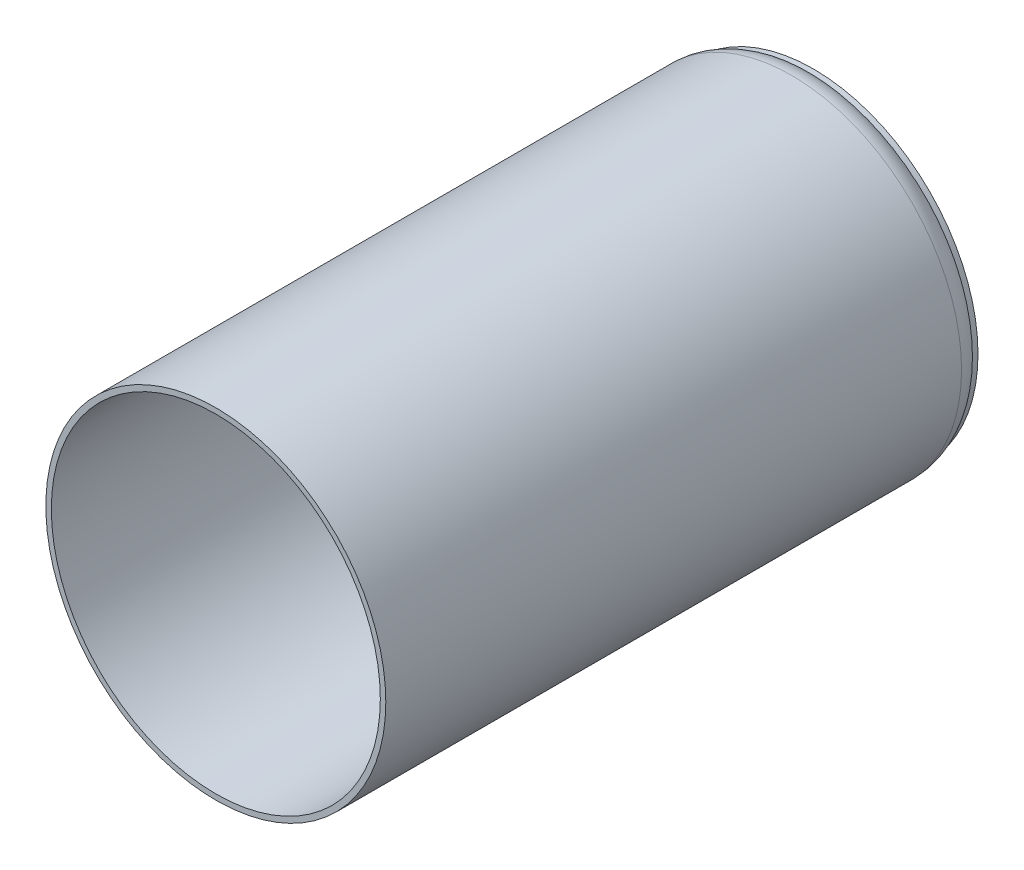
from build123d import *

# Parameters (mm, degrees)
SKETCH1_R           = 31
BOSS_EXTRUDE1_DEPTH = 110
SHELL1_T            = -1
FILLET2_R           = 5


with BuildPart() as part:
    # Sketch1 → Boss-Extrude1 (new body)
    with BuildSketch(Plane.XY):
        with Locations((-27.512537488, 7.30607002)):
            Circle(SKETCH1_R)
    extrude(amount=BOSS_EXTRUDE1_DEPTH)

    # Shell1
    shell1_openings = [part.faces().sort_by_distance(p)[0] for p in [
        (3.487462512, 7.30607002, 110),
    ]]
    offset(amount=SHELL1_T, openings=shell1_openings, kind=Kind.INTERSECTION)

    # Fillet2
    fillet2_edges = [part.edges().sort_by_distance(p)[0] for p in [
        (-58.512537488, 7.30607002, 0),
    ]]
    fillet(fillet2_edges, radius=FILLET2_R)


solid = part.part
